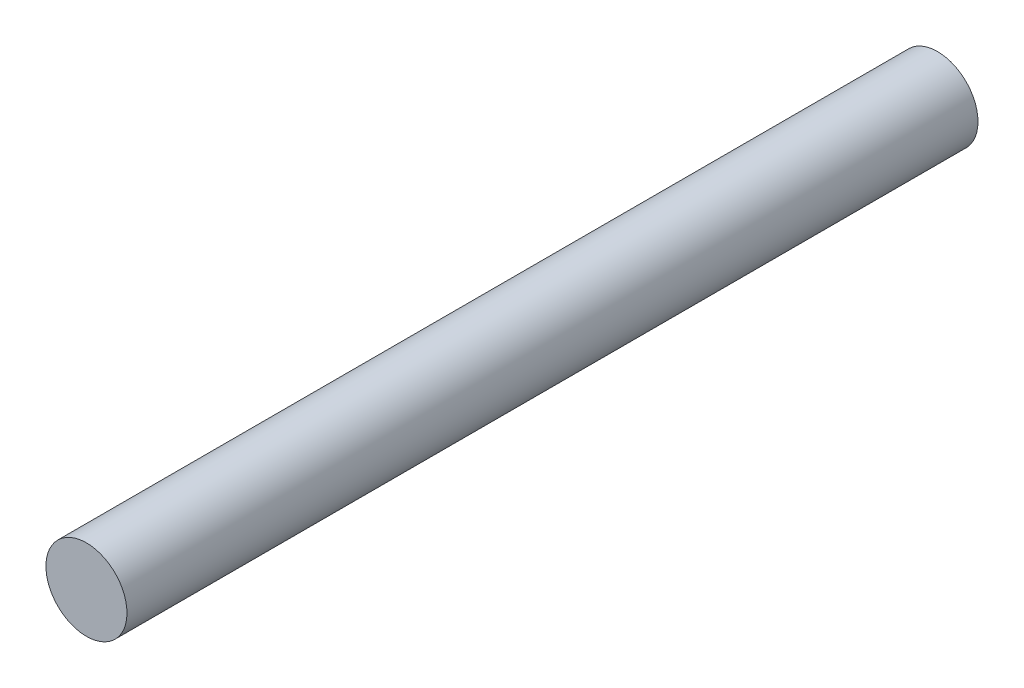
from build123d import *

# Parameters (mm, degrees)
SKETCH1_R           = 4
BOSS_EXTRUDE1_DEPTH = 84


with BuildPart() as part:
    # Sketch1 → Boss-Extrude1 (new body)
    with BuildSketch(Plane.XY):
        Circle(SKETCH1_R)
    extrude(amount=BOSS_EXTRUDE1_DEPTH)


solid = part.part
